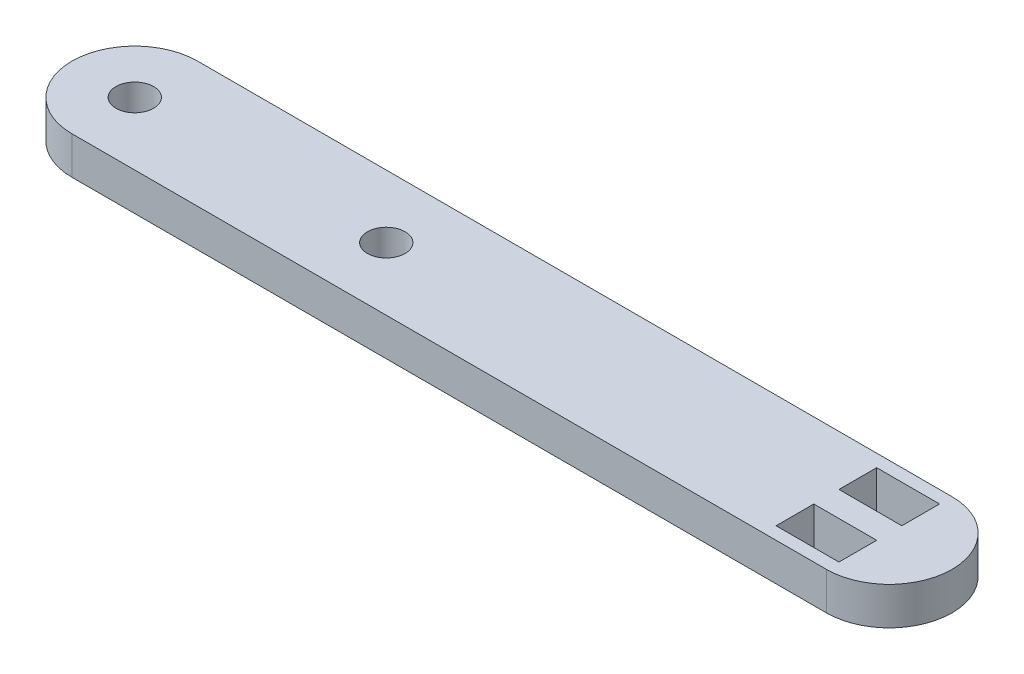
from build123d import *

# Parameters (mm, degrees)
SKETCH1_R           = 1.5
SKETCH1_W           = 5
SKETCH1_H           = 3
BOSS_EXTRUDE1_DEPTH = 3


with BuildPart() as part:
    # Sketch1 → Boss-Extrude1 (new body)
    with BuildSketch(Plane(origin=(0, 0, 0), x_dir=(1, 0, 0), z_dir=(0, 1, 0))):
        with BuildLine():
            Line((0, 0), (-60, 0))
            ThreePointArc((-60, 0), (-65, 5), (-60, 10))
            Line((-60, 10), (0, 10))
            ThreePointArc((0, 10), (5, 5), (0, 0))
        make_face()
        with Locations((-60, 5)):
            Circle(SKETCH1_R, mode=Mode.SUBTRACT)
        with Locations((-40, 5)):
            Circle(SKETCH1_R, mode=Mode.SUBTRACT)
        with Locations((-2.5, 2.5)):
            Rectangle(SKETCH1_W, SKETCH1_H, mode=Mode.SUBTRACT)
        with Locations((-2.5, 7.5)):
            Rectangle(SKETCH1_W, SKETCH1_H, mode=Mode.SUBTRACT)
    extrude(amount=BOSS_EXTRUDE1_DEPTH)


solid = part.part
